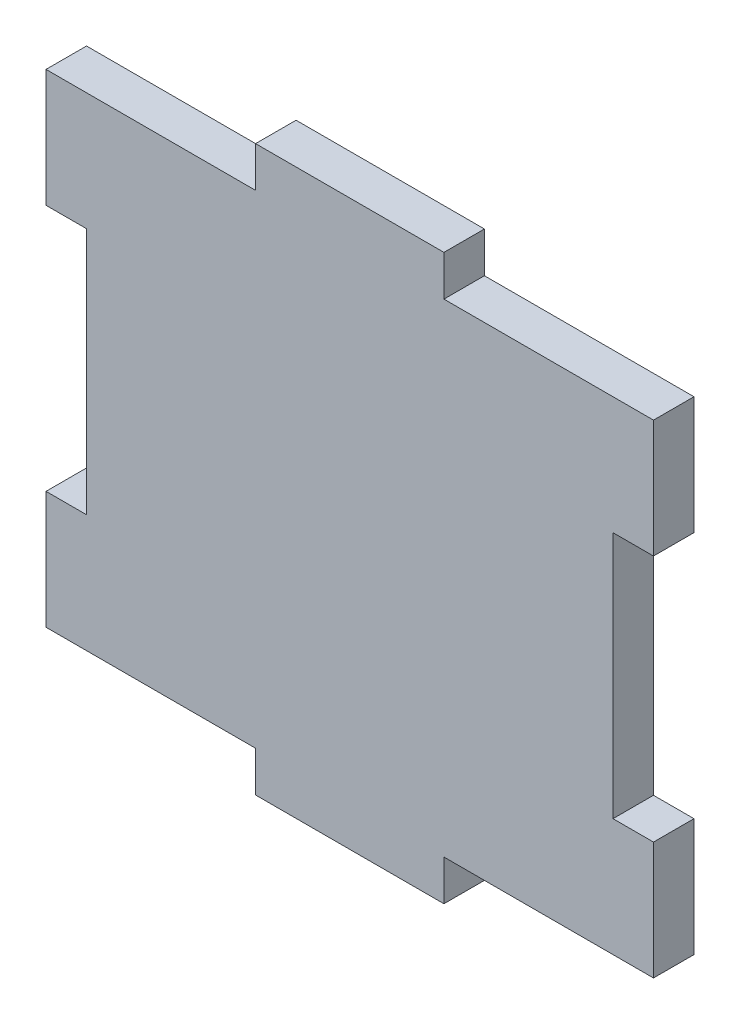
from build123d import *

# Parameters (mm, degrees)
SKETCH1_W           = 81.915
SKETCH1_H           = 65.151
BOSS_EXTRUDE1_DEPTH = 5.461
SKETCH2_W           = 5.461
SKETCH2_H           = 33.401
CUT_EXTRUDE1_DEPTH  = 6.461
SKETCH5_W           = 25.4
SKETCH5_H           = 5.461
BOSS_EXTRUDE2_DEPTH = 5.461


with BuildPart() as part:
    # Sketch1 → Boss-Extrude1 (new body)
    with BuildSketch(Plane.XY):
        Rectangle(SKETCH1_W, SKETCH1_H)
    extrude(amount=BOSS_EXTRUDE1_DEPTH)

    # Sketch2 → Cut-Extrude1 (cut, through all)
    with BuildSketch(Plane.XY.offset(5.461)):
        with Locations((-38.227, 0)):
            Rectangle(SKETCH2_W, SKETCH2_H)
        with Locations((38.227, 0)):
            Rectangle(SKETCH2_W, SKETCH2_H)
    extrude(amount=-CUT_EXTRUDE1_DEPTH, mode=Mode.SUBTRACT)

    # Sketch5 → Boss-Extrude2 (add)
    with BuildSketch(Plane(origin=(0, 0, 0), x_dir=(-1, 0, 0), z_dir=(0, 0, -1))):
        with Locations((0, 35.306)):
            Rectangle(SKETCH5_W, SKETCH5_H)
        with Locations((0, -35.306)):
            Rectangle(SKETCH5_W, SKETCH5_H)
    extrude(amount=-BOSS_EXTRUDE2_DEPTH)


solid = part.part
